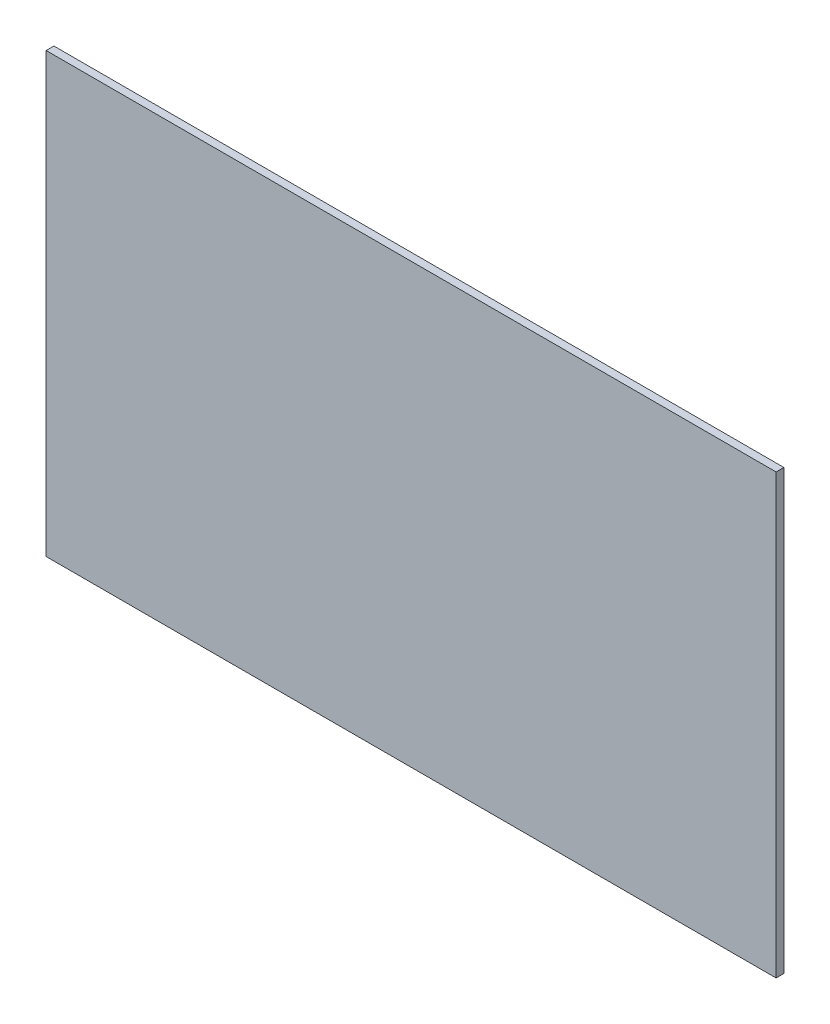
from build123d import *

# Parameters (mm, degrees)
ESQUISSE1_W        = 1126
ESQUISSE1_H        = 676
BOSS_EXTRU_1_DEPTH = 12


with BuildPart() as part:
    # Esquisse1 → Boss.-Extru.1 (new body)
    with BuildSketch(Plane.XY):
        Rectangle(ESQUISSE1_W, ESQUISSE1_H)
    extrude(amount=BOSS_EXTRU_1_DEPTH)


solid = part.part
